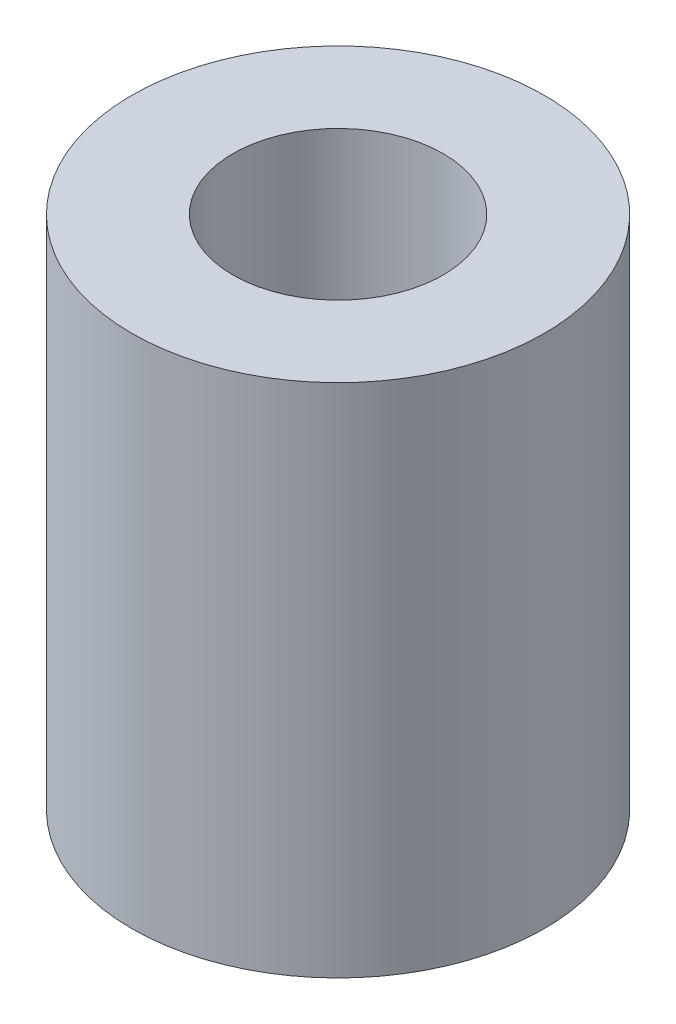
from build123d import *

# Parameters (mm, degrees)
SKIZZE1_R                 = 10
ZAPFEN_DEPTH              = 25
M12_GEWINDEBOHRUNG1_D     = 10.2
M12_GEWINDEBOHRUNG1_DEPTH = 20
M12_GEWINDEBOHRUNG1_TIP   = 3.064389157


with BuildPart() as part:
    # Skizze1 → Zapfen (new body)
    with BuildSketch(Plane(origin=(0, 0, 0), x_dir=(1, 0, 0), z_dir=(0, 1, 0))):
        with Locations(Location((0, 0, 0), (0, 0, 270))):  # turned: the seam where the file's is
            Circle(SKIZZE1_R)
    extrude(amount=ZAPFEN_DEPTH)

    # M12 Gewindebohrung1
    with Locations(Plane(origin=(0, 25, 0), x_dir=(1, 0, 0), z_dir=(0, 1, 0))):
        with Locations((0, 0)):
            Hole(M12_GEWINDEBOHRUNG1_D / 2, depth=M12_GEWINDEBOHRUNG1_DEPTH)
            with Locations((0, 0, -(M12_GEWINDEBOHRUNG1_DEPTH + M12_GEWINDEBOHRUNG1_TIP / 2))):  # 118° drill point
                Cone(0, M12_GEWINDEBOHRUNG1_D / 2, M12_GEWINDEBOHRUNG1_TIP, mode=Mode.SUBTRACT)


solid = part.part
